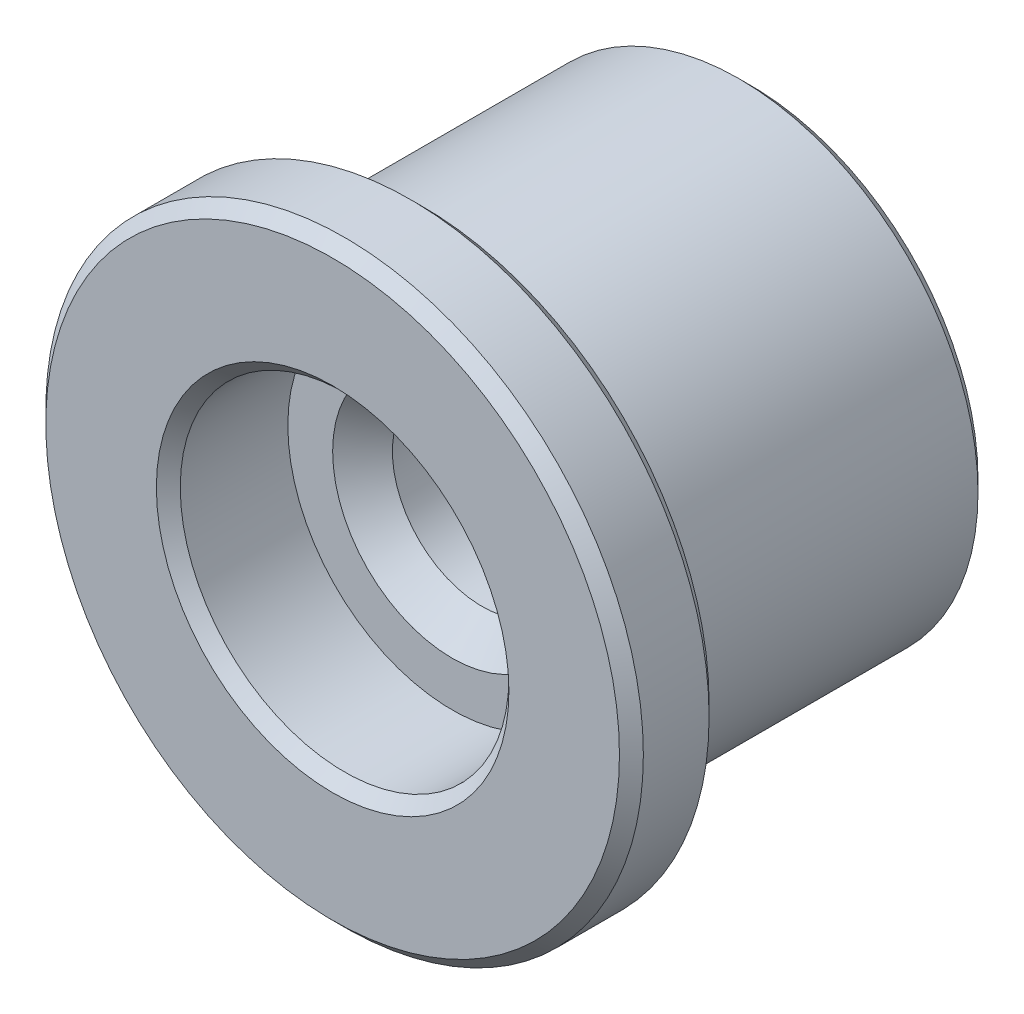
from build123d import *

# Parameters (mm, degrees)
SKETCH_1_R          = 4
EXTRUDE_1_DEPTH     = 5.5
SKETCH_2_R          = 5
EXTRUDE_2_DEPTH     = 1.5
SKETCH_3_R          = 2.75
CUT_EXTRUDE_1_DEPTH = 2
SKETCH_4_R          = 1.5
CUT_EXTRUDE_2_DEPTH = 8
CHAMFER_1_SIZE      = 0.2
CHAMFER_2_SIZE      = 0.2
CHAMFER_3_SIZE      = 0.2
CHAMFER_4_SIZE      = 0.5


with BuildPart() as part:
    # 草图1 → 拉伸1 (new body)
    with BuildSketch(Plane.XY):
        Circle(SKETCH_1_R)
    extrude(amount=EXTRUDE_1_DEPTH)

    # 草图2 → 拉伸2 (add)
    with BuildSketch(Plane.XY.offset(5.5)):
        Circle(SKETCH_2_R)
    extrude(amount=EXTRUDE_2_DEPTH)

    # 草图3 → 切除-拉伸1 (cut)
    with BuildSketch(Plane.XY.offset(7)):
        Circle(SKETCH_3_R)
    extrude(amount=-CUT_EXTRUDE_1_DEPTH, mode=Mode.SUBTRACT)

    # 草图4 → 切除-拉伸2 (cut, through all)
    with BuildSketch(Plane(origin=(0, 0, 0), x_dir=(-1, 0, 0), z_dir=(0, 0, -1))):
        Circle(SKETCH_4_R)
    extrude(amount=-CUT_EXTRUDE_2_DEPTH, mode=Mode.SUBTRACT)

    # 倒角1
    chamfer_1_edges = [part.edges().sort_by_distance(p)[0] for p in [
        (-5, 0, 5.5),
        (-5, 0, 7),
    ]]
    chamfer(chamfer_1_edges, length=CHAMFER_1_SIZE)

    # 倒角2
    chamfer_2_edges = [part.edges().sort_by_distance(p)[0] for p in [
        (-4, 0, 0),
    ]]
    chamfer(chamfer_2_edges, length=CHAMFER_2_SIZE)

    # 倒角3
    chamfer_3_edges = [part.edges().sort_by_distance(p)[0] for p in [
        (-2.75, 0, 7),
    ]]
    chamfer(chamfer_3_edges, length=CHAMFER_3_SIZE)

    # 倒角4
    chamfer_4_edges = [part.edges().sort_by_distance(p)[0] for p in [
        (1.5, 0, 5),
        (1.5, 0, 0),
    ]]
    chamfer(chamfer_4_edges, length=CHAMFER_4_SIZE)


solid = part.part
